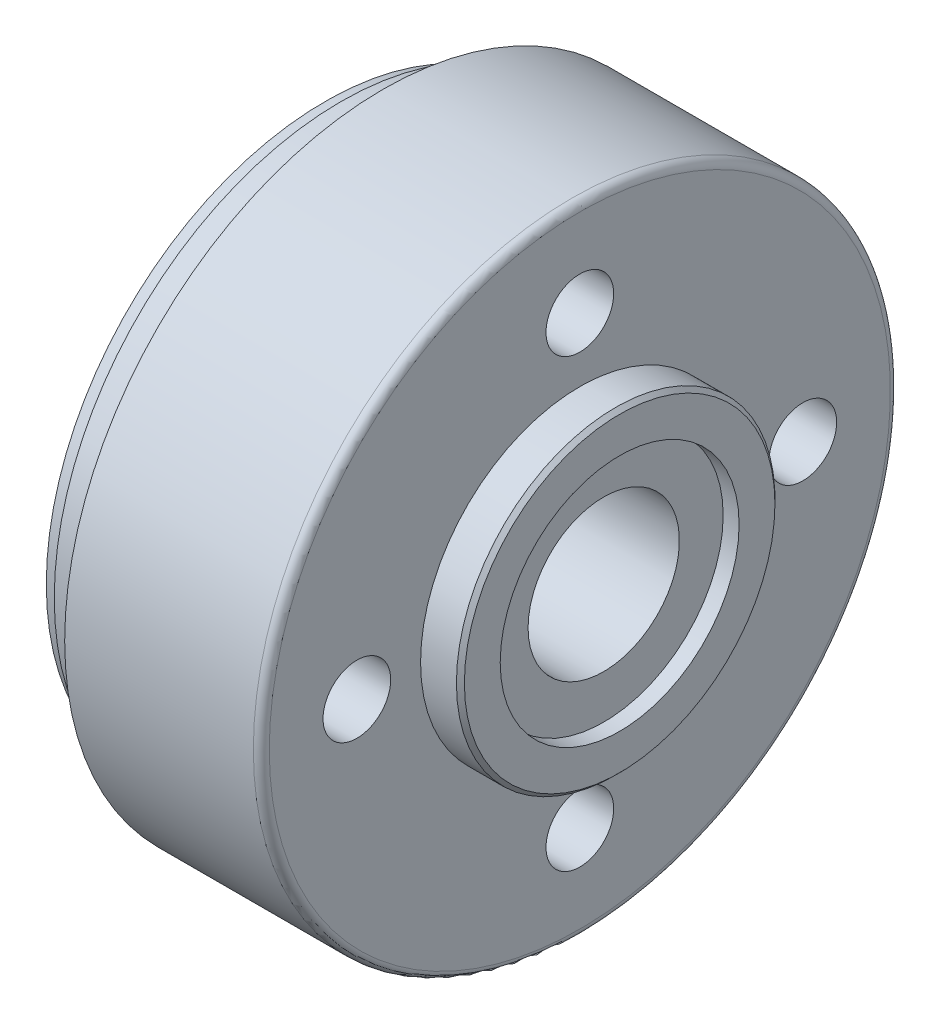
from build123d import *

# Parameters (mm, degrees)
REJFNING_0_5_X_45_GR_SIZE = 0.5
RUNDING_R1_R              = 1
HOLE1_D                   = 8.5
HOLE1_DEPTH               = 17.5
HOLE1_TIP                 = 2.553657631


with BuildPart() as part:
    # Sketch1 → Base-Revolve (revolve)
    with BuildSketch(Plane.XY):
        Polygon((0, 9.5), (35, 9.5), (35, 15), (37, 15), (37, 20), (32, 20), (32, 40), (7.309401077, 40), (5, 36), (2, 36), (2, 35), (0, 35), align=None)
    revolve(axis=Axis((-31.276903974, 0, 0), (1, 0, 0)))

    # Rejfning 0,5 x 45 gr.
    rejfning_0_5_x_45_gr_edges = [part.edges().sort_by_distance(p)[0] for p in [
        (37, -20, 0),
    ]]
    chamfer(rejfning_0_5_x_45_gr_edges, length=REJFNING_0_5_X_45_GR_SIZE)

    # Runding R1
    runding_r1_edges = [part.edges().sort_by_distance(p)[0] for p in [
        (32, -40, 0),
    ]]
    fillet(runding_r1_edges, radius=RUNDING_R1_R)

    # Hole1
    with Locations(Plane(origin=(32, 0, 0), x_dir=(0, 0, -1), z_dir=(1, 0, 0))):
        with Locations((0, 28), (-28, 0), (0, -28), (28, 0)):
            Hole(HOLE1_D / 2, depth=HOLE1_DEPTH)
            with Locations((0, 0, -(HOLE1_DEPTH + HOLE1_TIP / 2))):  # 118° drill point
                Cone(0, HOLE1_D / 2, HOLE1_TIP, mode=Mode.SUBTRACT)


solid = part.part
